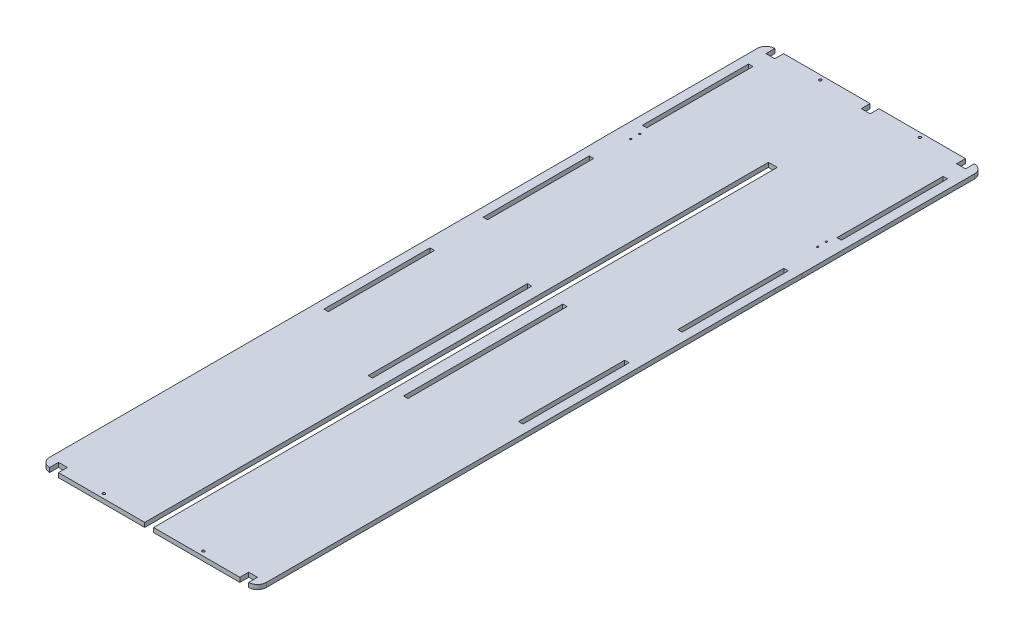
from build123d import *

# Parameters (mm, degrees)
SKETCH2_R           = 1.5
SKETCH2_W           = 5
SKETCH2_H           = 120
BOSS_EXTRUDE1_DEPTH = 5
SKETCH3_R           = 1
SKETCH3_W           = 5
SKETCH3_H           = 180
CUT_EXTRUDE1_DEPTH  = 5
FILLET1_R           = 10
SKETCH4_W           = 10
SKETCH4_H           = 10
CUT_EXTRUDE2_DEPTH  = 10


with BuildPart() as part:
    # Sketch2 → Boss-Extrude1 (new body)
    with BuildSketch(Plane(origin=(0, 0, 0), x_dir=(1, 0, 0), z_dir=(0, 1, 0))):
        Polygon((0, 375), (0, 0), (0, -230), (10, -230), (15, -230), (117.5, -230), (117.5, 475), (127.5, 475), (127.5, -230), (230, -230), (235, -230), (245, -230), (245, -10), (245, 355), (245.3, 385), (245.3, 590), (245, 590), (0, 590), (-0.3, 590), (-0.3, 405), align=None)
        with Locations((66.25, -225)):
            Circle(SKETCH2_R, mode=Mode.SUBTRACT)
        with Locations((12.5, 140)):
            Rectangle(SKETCH2_W, SKETCH2_H, mode=Mode.SUBTRACT)
        with Locations((178.75, -225)):
            Circle(SKETCH2_R, mode=Mode.SUBTRACT)
        with Locations((232.5, 140)):
            Rectangle(SKETCH2_W, SKETCH2_H, mode=Mode.SUBTRACT)
        with Locations((12.5, 320)):
            Rectangle(SKETCH2_W, SKETCH2_H, mode=Mode.SUBTRACT)
        with Locations((12.5, 500)):
            Rectangle(SKETCH2_W, SKETCH2_H, mode=Mode.SUBTRACT)
        with Locations((66.25, 585)):
            Circle(SKETCH2_R, mode=Mode.SUBTRACT)
        with Locations((232.5, 320)):
            Rectangle(SKETCH2_W, SKETCH2_H, mode=Mode.SUBTRACT)
        with Locations((178.75, 585)):
            Circle(SKETCH2_R, mode=Mode.SUBTRACT)
        with Locations((232.5, 500)):
            Rectangle(SKETCH2_W, SKETCH2_H, mode=Mode.SUBTRACT)
    extrude(amount=BOSS_EXTRUDE1_DEPTH)

    # Sketch3 → Cut-Extrude1 (cut)
    with BuildSketch(Plane(origin=(0, 5, 0), x_dir=(1, 0, 0), z_dir=(0, 1, 0))):
        with Locations((17, 420)):
            Circle(SKETCH3_R)
        with Locations((17, 430)):
            Circle(SKETCH3_R)
        with Locations((102.5, 130)):
            Rectangle(SKETCH3_W, SKETCH3_H)
    cut_extrude1 = extrude(amount=-CUT_EXTRUDE1_DEPTH, mode=Mode.SUBTRACT)

    # Mirror1: Cut-Extrude1 across plane
    add(cut_extrude1.mirror(Plane.ZY.offset(-122.5)), mode=Mode.SUBTRACT)

    # Fillet1
    fillet1_edges = [part.edges().sort_by_distance(p)[0] for p in [
        (245, 2.5, 230),
        (0, 2.5, 230),
        (-0.3, 2.5, -590),
        (245.3, 2.5, -590),
    ]]
    fillet(fillet1_edges, radius=FILLET1_R)

    # Sketch4 → Cut-Extrude2 (cut)
    with BuildSketch(Plane(origin=(0, 5, 0), x_dir=(1, 0, 0), z_dir=(0, 1, 0))):
        with Locations((15, -225)):
            Rectangle(SKETCH4_W, SKETCH4_H)
        with Locations((230, -225)):
            Rectangle(SKETCH4_W, SKETCH4_H)
        with Locations((14.7, 585)):
            Rectangle(SKETCH4_W, SKETCH4_H)
        with Locations((230.3, 585)):
            Rectangle(SKETCH4_W, SKETCH4_H)
        with Locations((122.5, 585)):
            Rectangle(SKETCH4_W, SKETCH4_H)
    extrude(amount=-CUT_EXTRUDE2_DEPTH, mode=Mode.SUBTRACT)


solid = part.part
